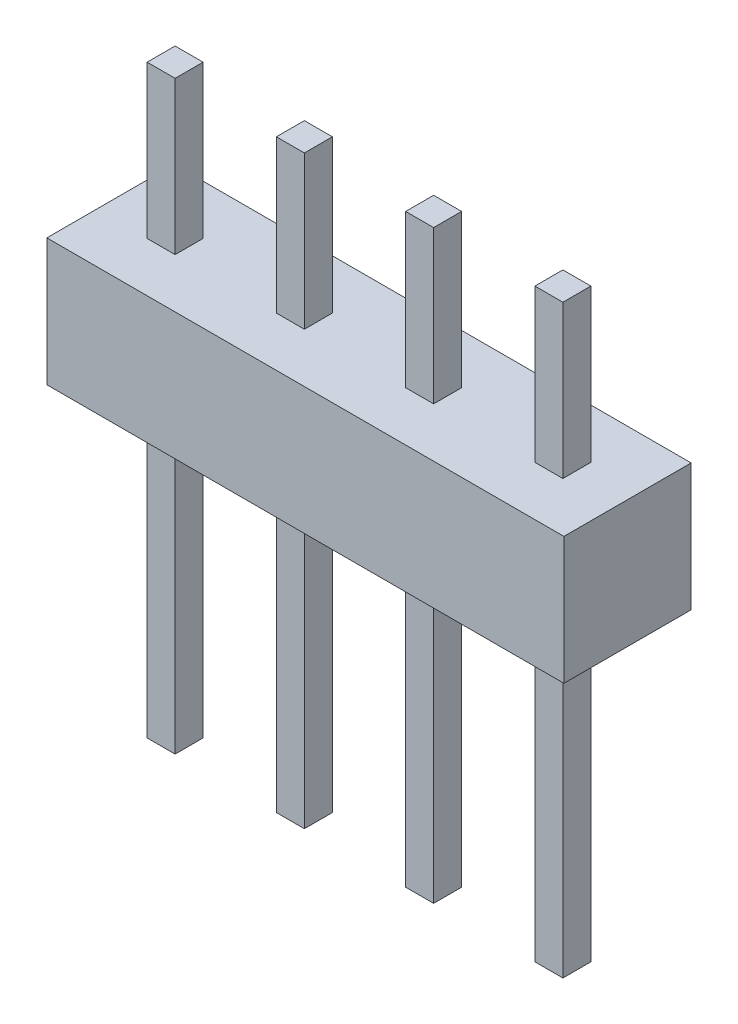
from build123d import *

# Parameters (mm, degrees)
SKETCH1_W             = 10.16
SKETCH1_H             = 2.5
BOSS_EXTRUDE1_DEPTH   = 1.25
SKETCH2_W             = 0.55
SKETCH2_H             = 0.55
BOSS_EXTRUDE2_DEPTH   = 6
BOSS_EXTRUDE2_2_DEPTH = 6
BOSS_EXTRUDE2_3_DEPTH = 6
BOSS_EXTRUDE2_4_DEPTH = 6
SKETCH2_2_W           = 0.55
SKETCH2_2_H           = 0.55
BOSS_EXTRUDE3_DEPTH   = 5.5
BOSS_EXTRUDE3_2_DEPTH = 5.5
BOSS_EXTRUDE3_3_DEPTH = 5.5
BOSS_EXTRUDE3_4_DEPTH = 5.5


with BuildPart() as part:
    # Sketch1 → Boss-Extrude1 (new body, symmetric)
    with BuildSketch(Plane.XY):
        with Locations((5.08, 1.25)):
            Rectangle(SKETCH1_W, SKETCH1_H)
    extrude(amount=BOSS_EXTRUDE1_DEPTH, both=True)


with BuildPart() as body_2:
    # Sketch2 → Boss-Extrude2 (new body)
    with BuildSketch(Plane.XZ):
        with Locations((3.81, 0)):
            Rectangle(SKETCH2_W, SKETCH2_H)
    extrude(amount=BOSS_EXTRUDE2_DEPTH)


with BuildPart() as body_3:
    # Sketch2 → Boss-Extrude2 2 (new body)
    with BuildSketch(Plane.XZ):
        with Locations((1.27, 0)):
            Rectangle(SKETCH2_W, SKETCH2_H)
    extrude(amount=BOSS_EXTRUDE2_2_DEPTH)


with BuildPart() as body_4:
    # Sketch2 → Boss-Extrude2 3 (new body)
    with BuildSketch(Plane.XZ):
        with Locations((6.35, 0)):
            Rectangle(SKETCH2_W, SKETCH2_H)
    extrude(amount=BOSS_EXTRUDE2_3_DEPTH)


with BuildPart() as body_5:
    # Sketch2 → Boss-Extrude2 4 (new body)
    with BuildSketch(Plane.XZ):
        with Locations((8.89, 0)):
            Rectangle(SKETCH2_W, SKETCH2_H)
    extrude(amount=BOSS_EXTRUDE2_4_DEPTH)


with BuildPart() as body_6:
    # Sketch2_2 → Boss-Extrude3 (new body)
    with BuildSketch(Plane.XZ):
        with Locations((3.81, 0)):
            Rectangle(SKETCH2_2_W, SKETCH2_2_H)
    extrude(amount=-BOSS_EXTRUDE3_DEPTH)


with BuildPart() as body_7:
    # Sketch2_2 → Boss-Extrude3 2 (new body)
    with BuildSketch(Plane.XZ):
        with Locations((1.27, 0)):
            Rectangle(SKETCH2_2_W, SKETCH2_2_H)
    extrude(amount=-BOSS_EXTRUDE3_2_DEPTH)


with BuildPart() as body_8:
    # Sketch2_2 → Boss-Extrude3 3 (new body)
    with BuildSketch(Plane.XZ):
        with Locations((6.35, 0)):
            Rectangle(SKETCH2_2_W, SKETCH2_2_H)
    extrude(amount=-BOSS_EXTRUDE3_3_DEPTH)


with BuildPart() as body_9:
    # Sketch2_2 → Boss-Extrude3 4 (new body)
    with BuildSketch(Plane.XZ):
        with Locations((8.89, 0)):
            Rectangle(SKETCH2_2_W, SKETCH2_2_H)
    extrude(amount=-BOSS_EXTRUDE3_4_DEPTH)


solid = Compound([part.part, body_2.part, body_3.part, body_4.part, body_5.part, body_6.part, body_7.part, body_8.part, body_9.part])
